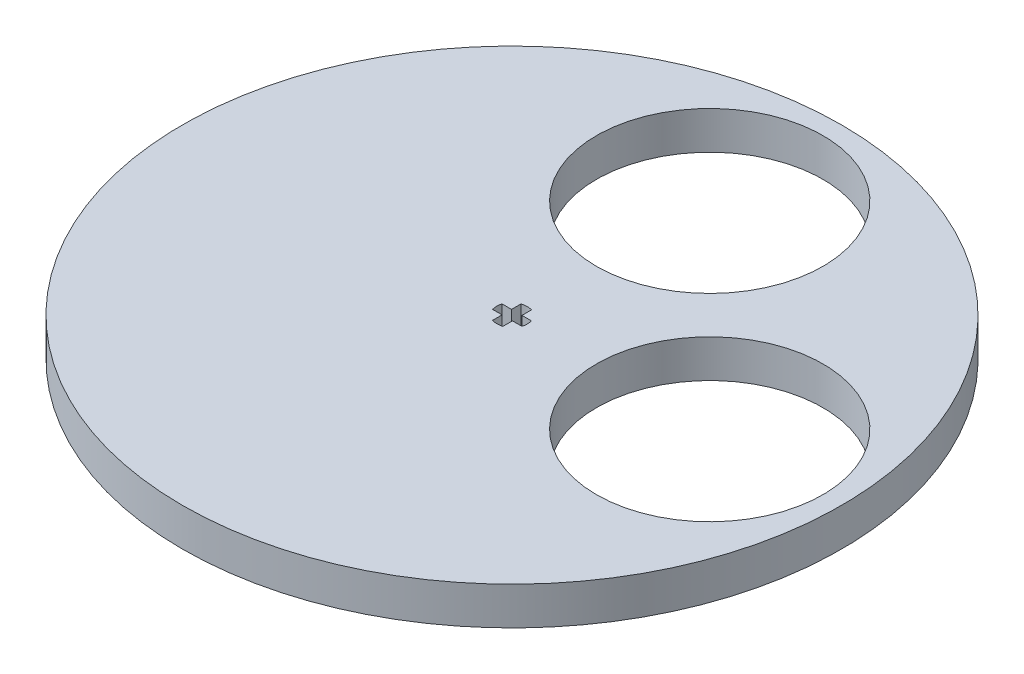
from build123d import *

# Parameters (mm, degrees)
SKETCH6_R           = 50.8
BOSS_EXTRUDE3_DEPTH = 5.842
CUT_EXTRUDE2_DEPTH  = 6.842
SKETCH12_R          = 2.75
CUT_EXTRUDE3_DEPTH  = 6.842
SKETCH12_3_R        = 2.75
BOSS_EXTRUDE4_DEPTH = 5.842


with BuildPart() as part:
    # Sketch6 → Boss-Extrude3 (new body)
    with BuildSketch(Plane(origin=(0, 0, 0), x_dir=(1, 0, 0), z_dir=(0, 1, 0))):
        with Locations((63.5, 63.5)):
            Circle(SKETCH6_R)
    extrude(amount=BOSS_EXTRUDE3_DEPTH)

    # Sketch11 → Cut-Extrude2 (cut, through all)
    with BuildSketch(Plane(origin=(0, 5.842, 0), x_dir=(1, 0, 0), z_dir=(0, 1, 0))):
        with BuildLine():
            ThreePointArc((80.9625, 93.98), (75.847852166, 106.327852166), (63.5, 111.4425))
            Line((63.5, 111.4425), (63.5, 76.5175))
            ThreePointArc((63.5, 76.5175), (75.847852166, 81.632147834), (80.9625, 93.98))
        make_face()
        with BuildLine():
            Line((63.5, 76.5175), (63.5, 111.4425))
            ThreePointArc((63.5, 111.4425), (46.0375, 93.98), (63.5, 76.5175))
        make_face()
        with BuildLine():
            ThreePointArc((111.4425, 63.5), (93.98, 80.9625), (76.5175, 63.5))
            Line((76.5175, 63.5), (111.4425, 63.5))
        make_face()
        with BuildLine():
            Line((111.4425, 63.5), (76.5175, 63.5))
            ThreePointArc((76.5175, 63.5), (93.98, 46.0375), (111.4425, 63.5))
        make_face()
    extrude(amount=-CUT_EXTRUDE2_DEPTH, mode=Mode.SUBTRACT)

    # Sketch12 → Cut-Extrude3 (cut, through all)
    with BuildSketch(Plane(origin=(0, 5.842, 0), x_dir=(1, 0, 0), z_dir=(0, 1, 0))):
        with Locations((63.5, 63.5)):
            Circle(SKETCH12_R)
    extrude(amount=-CUT_EXTRUDE3_DEPTH, mode=Mode.SUBTRACT)

    # Sketch12_3 → Boss-Extrude4 (add)
    with BuildSketch(Plane(origin=(0, 5.842, 0), x_dir=(1, 0, 0), z_dir=(0, 1, 0))):
        with Locations((63.5, 63.5)):
            Circle(SKETCH12_3_R)
        with BuildLine():
            Line((62.7, 64.23137085), (62.7, 65.69411255))
            ThreePointArc((62.7, 65.69411255), (63.5, 65.820249175), (64.3, 65.69411255))
            Line((64.3, 65.69411255), (64.3, 64.23137085))
            Line((64.3, 64.23137085), (65.7627417, 64.23137085))
            ThreePointArc((65.7627417, 64.23137085), (65.867727335, 63.5), (65.7627417, 62.76862915))
            Line((65.7627417, 62.76862915), (64.3, 62.76862915))
            Line((64.3, 62.76862915), (64.3, 61.30588745))
            ThreePointArc((64.3, 61.30588745), (63.5, 61.179750825), (62.7, 61.30588745))
            Line((62.7, 61.30588745), (62.7, 62.76862915))
            Line((62.7, 62.76862915), (61.2372583, 62.76862915))
            ThreePointArc((61.2372583, 62.76862915), (61.132272665, 63.5), (61.2372583, 64.23137085))
            Line((61.2372583, 64.23137085), (62.7, 64.23137085))
        make_face(mode=Mode.SUBTRACT)
    extrude(amount=-BOSS_EXTRUDE4_DEPTH)


solid = part.part
